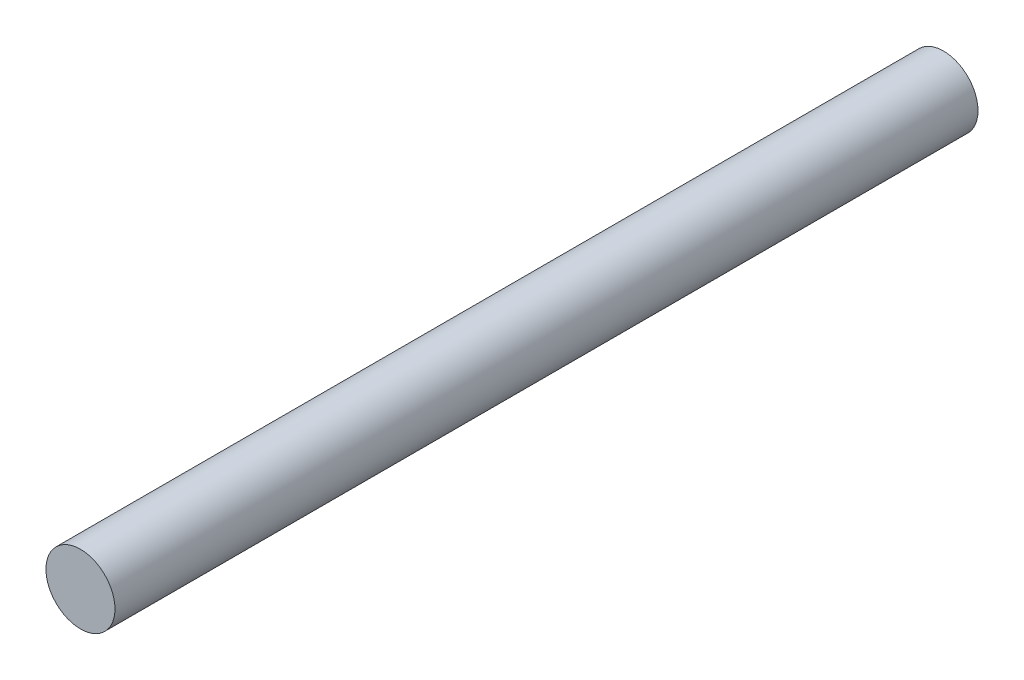
from build123d import *

# Parameters (mm, degrees)
SKETCH1_R           = 5
BOSS_EXTRUDE1_DEPTH = 125


with BuildPart() as part:
    # Sketch1 → Boss-Extrude1 (new body)
    with BuildSketch(Plane.XY):
        Circle(SKETCH1_R)
    extrude(amount=BOSS_EXTRUDE1_DEPTH)


solid = part.part
